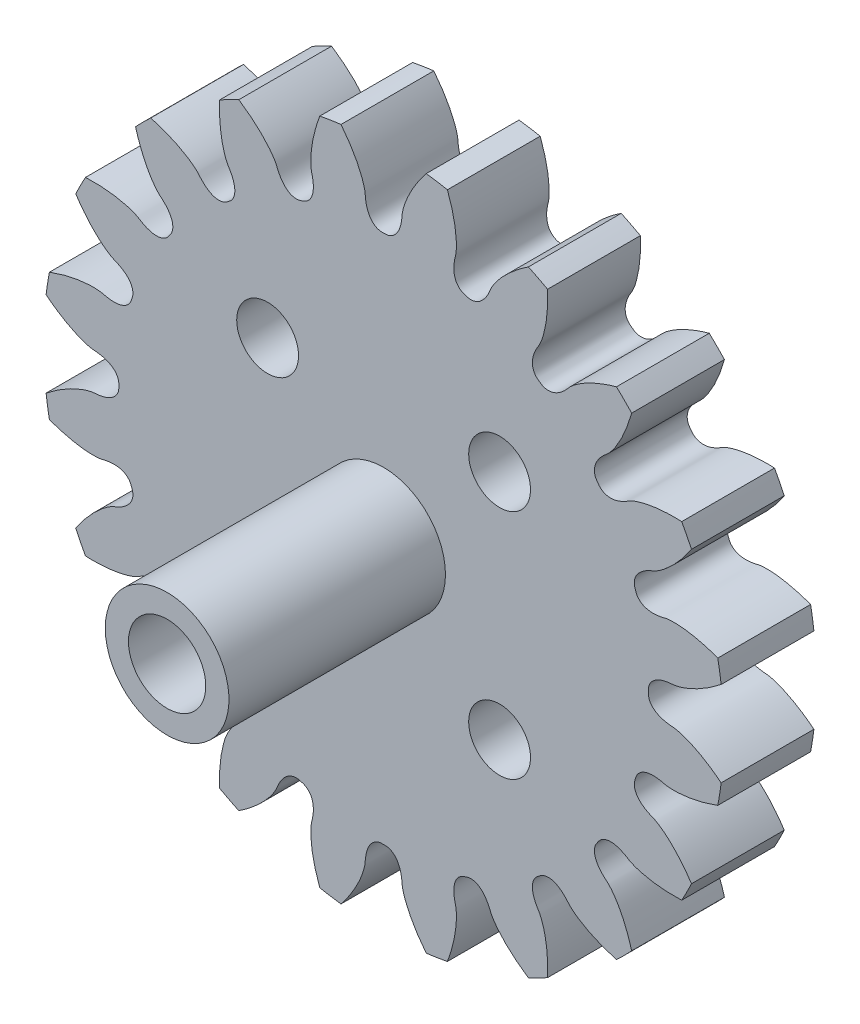
from build123d import *

# Parameters (mm, degrees)
SKETCHREVOLVESPURGEAR_W       = 6
SKETCHREVOLVESPURGEAR_H       = 22.000016431
TOOTHEXTRUDECUTSPURGEAR_DEPTH = 3
PATTERNSPURGEAR_COUNT         = 20
BOREREVOLVESKETCH_W           = 6
BOREREVOLVESKETCH_H           = 4
BOSS_EXTRUDE1_START           = -20
SKETCH1_R                     = 4
SKETCH1_R_2                   = 2.5
BOSS_EXTRUDE1_DEPTH           = 20
SKETCH2_R                     = 2
CUT_EXTRUDE1_DEPTH            = 6


with BuildPart() as part:
    # SketchRevolveSpurGear → SpurGear (revolve)
    with BuildSketch(Plane(origin=(0, 0, 0), x_dir=(0, 0, -1), z_dir=(1, 0, 0))):
        with Locations((0, 11.000008216)):
            Rectangle(SKETCHREVOLVESPURGEAR_W, SKETCHREVOLVESPURGEAR_H)
    revolve(axis=Axis((0, 0, 0), (0, 0, -1)))

    # SketchToothSpurGear → ToothExtrudeCutSpurGear (cut, symmetric)
    with BuildSketch(Plane.XY):
        with BuildLine():
            ThreePointArc((21.918437938, 2.827155452), (22.100016506, 0), (21.918437938, -2.827155452))
            add(Edge.make_bspline(
                [(21.918437938, -2.827155452), (21.741634494, -2.683511533), (21.47724659, -2.481241403), (21.122290208, -2.235560306), (20.873154524, -2.074277501), (20.63454821, -1.930073153), (20.407274596, -1.802133008), (20.192096454, -1.689609545), (19.989734719, -1.591624181), (19.800867311, -1.507268956), (19.626128022, -1.435608337), (19.466105478, -1.375681255), (19.321342163, -1.326502463), (19.192333558, -1.287066224), (19.079527231, -1.256342915), (18.983322364, -1.233297241), (18.904068332, -1.216843484), (18.842066178, -1.205976604), (18.732442227, -1.189891819), (18.620782096, -1.188760334), (18.504026603, -1.176167574), (18.441057897, -1.168560118), (18.379311055, -1.159731766), (18.318763238, -1.149824549), (18.259406779, -1.138800627), (18.201227777, -1.126664796), (18.144211661, -1.113405645), (18.088341766, -1.099010149), (18.033599791, -1.083458923), (17.979965867, -1.066726409), (17.927418857, -1.048779608), (17.875936773, -1.029577027), (17.825497411, -1.009067392), (17.776079251, -0.987188242), (17.727662726, -0.963864394), (17.680231956, -0.939006319), (17.633777098, -0.91250851), (17.588297456, -0.88424794), (17.543805547, -0.854082845), (17.500332301, -0.821852091), (17.457933556, -0.787375583), (17.416697933, -0.750456311), (17.376756016, -0.710884806), (17.338290456, -0.668446963), (17.301546205, -0.622936269), (17.266839338, -0.574171347), (17.234562572, -0.522019258), (17.20518339, -0.466424111), (17.179235988, -0.407438556), (17.157286748, -0.345255235), (17.139939668, -0.280227271), (17.127623678, -0.212888748), (17.121784286, -0.150526726), (17.119252793, -0.079416195), (17.121111495, 0), (17.119252793, 0.079416195), (17.121784286, 0.150526726), (17.127623678, 0.212888748), (17.139939668, 0.280227271), (17.157286748, 0.345255235), (17.179235988, 0.407438556), (17.20518339, 0.466424111), (17.234562572, 0.522019258), (17.266839338, 0.574171347), (17.301546205, 0.622936269), (17.338290456, 0.668446963), (17.376756016, 0.710884806), (17.416697933, 0.750456311), (17.457933556, 0.787375583), (17.500332301, 0.821852091), (17.543805547, 0.854082845), (17.588297456, 0.88424794), (17.633777098, 0.91250851), (17.680231956, 0.939006319), (17.727662726, 0.963864394), (17.776079251, 0.987188242), (17.825497411, 1.009067392), (17.875936773, 1.029577027), (17.927418857, 1.048779608), (17.979965867, 1.066726409), (18.033599791, 1.083458923), (18.088341766, 1.099010149), (18.144211661, 1.113405645), (18.201227777, 1.126664796), (18.259406779, 1.138800627), (18.318763238, 1.149824549), (18.379311055, 1.159731766), (18.441057897, 1.168560118), (18.504026603, 1.176167574), (18.620782096, 1.188760334), (18.732442227, 1.189891819), (18.842066178, 1.205976604), (18.904068332, 1.216843484), (18.983322364, 1.233297241), (19.079527231, 1.256342915), (19.192333558, 1.287066224), (19.321342163, 1.326502463), (19.466105478, 1.375681255), (19.626128022, 1.435608337), (19.800867311, 1.507268956), (19.989734719, 1.591624181), (20.192096454, 1.689609545), (20.407274596, 1.802133008), (20.63454821, 1.930073153), (20.873154524, 2.074277501), (21.122290208, 2.235560306), (21.47724659, 2.481241403), (21.741634494, 2.683511533), (21.918437938, 2.827155452)],
                knots=[0, 0, 0, 0, 0.058197086, 0.084998375, 0.110268162, 0.134006447, 0.15621323, 0.176888511, 0.196032289, 0.213644565, 0.229725339, 0.244274611, 0.257292381, 0.268778648, 0.278733413, 0.287156677, 0.294048438, 0.299408697, 0.303237455, 0.322342252, 0.327835185, 0.333235468, 0.338545795, 0.343769121, 0.348908689, 0.353968064, 0.358951167, 0.363862319, 0.368706284, 0.373488322, 0.378214239, 0.382890449, 0.387524035, 0.392122816, 0.396695408, 0.40125129, 0.405800854, 0.410355444, 0.414927364, 0.419529849, 0.424176967, 0.428883441, 0.433664351, 0.438534688, 0.443508725, 0.448599187, 0.453816228, 0.459166235, 0.464650592, 0.47026454, 0.475996383, 0.481827282, 0.487731843, 0.491980816, 0.5, 0.508019184, 0.512268157, 0.518172718, 0.524003617, 0.52973546, 0.535349408, 0.540833765, 0.546183772, 0.551400813, 0.556491275, 0.561465312, 0.566335649, 0.571116559, 0.575823033, 0.580470151, 0.585072636, 0.589644556, 0.594199146, 0.59874871, 0.603304592, 0.607877184, 0.612475965, 0.617109551, 0.621785761, 0.626511678, 0.631293716, 0.636137681, 0.641048833, 0.646031936, 0.651091311, 0.656230879, 0.661454205, 0.666764532, 0.672164815, 0.677657748, 0.696762545, 0.700591303, 0.705951562, 0.712843323, 0.721266587, 0.731221352, 0.742707619, 0.755725389, 0.770274661, 0.786355435, 0.803967711, 0.823111489, 0.84378677, 0.865993553, 0.889731838, 0.915001625, 0.941802914, 1, 1, 1, 1], degree=3))
        make_face()
    toothextrudecutspurgear = extrude(amount=TOOTHEXTRUDECUTSPURGEAR_DEPTH, both=True, mode=Mode.SUBTRACT)

    # PatternSpurGear: ToothExtrudeCutSpurGear ×20 about axis
    patternspurgear_axis = Axis((0, 0, 55), (0, 0, -1))
    for i in range(1, PATTERNSPURGEAR_COUNT):
        add(toothextrudecutspurgear.rotate(patternspurgear_axis, i * 360 / PATTERNSPURGEAR_COUNT), mode=Mode.SUBTRACT)

    # BoreRevolveSketch → BoreRevolveCut (revolve, cut)
    with BuildSketch(Plane(origin=(0, 0, 0), x_dir=(0, 0, -1), z_dir=(1, 0, 0))):
        with Locations((0, 2)):
            Rectangle(BOREREVOLVESKETCH_W, BOREREVOLVESKETCH_H)
    revolve(axis=Axis((0, 0, 0), (0, 0, -1)), mode=Mode.SUBTRACT)

    # Sketch1 → Boss-Extrude1 (add)
    with BuildSketch(Plane(origin=(0, 0, -3), x_dir=(-1, 0, 0), z_dir=(0, 0, -1)).offset(BOSS_EXTRUDE1_START)):
        Circle(SKETCH1_R)
        Circle(SKETCH1_R_2, mode=Mode.SUBTRACT)
    extrude(amount=BOSS_EXTRUDE1_DEPTH)

    # Sketch2 → Cut-Extrude1 (cut)
    with BuildSketch(Plane(origin=(0, 0, -3), x_dir=(-1, 0, 0), z_dir=(0, 0, -1))):
        with Locations((7.5, 7.5)):
            Circle(SKETCH2_R)
        with Locations((7.5, -7.5)):
            Circle(SKETCH2_R)
        with Locations((-7.5, -7.5)):
            Circle(SKETCH2_R)
        with Locations((-7.5, 7.5)):
            Circle(SKETCH2_R)
    extrude(amount=-CUT_EXTRUDE1_DEPTH, mode=Mode.SUBTRACT)


solid = part.part
